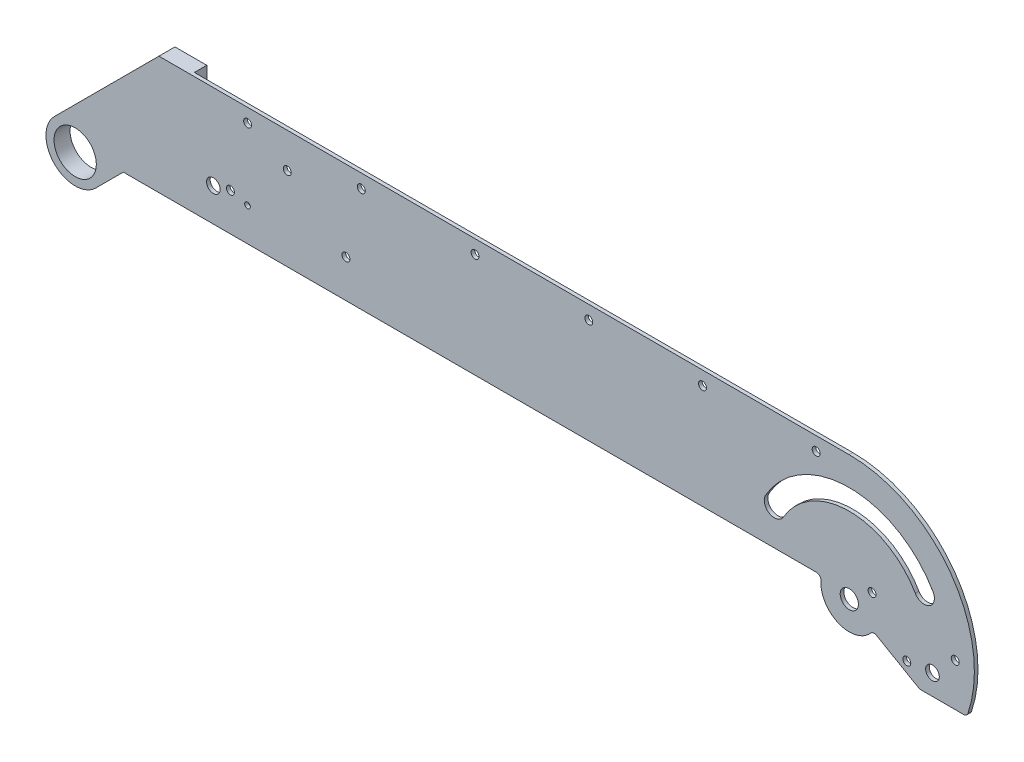
from build123d import *

# Parameters (mm, degrees)
SKETCH1_W           = 500
SKETCH1_H           = 150
SKETCH1_R           = 9.3
SKETCH1_R_2         = 3
SKETCH1_R_3         = 4
BOSS_EXTRUDE1_DEPTH = 1.5875
SKETCH3_W           = 500
SKETCH3_H           = 150
CUT_EXTRUDE1_DEPTH  = 7
SKETCH4_R           = 9.3
CUT_EXTRUDE2_DEPTH  = 10
FILLET1_R           = 2
SKETCH5_R           = 1.75
SKETCH5_R_2         = 1.25
SKETCH5_R_3         = 3
CUT_EXTRUDE3_DEPTH  = 10
CUT_EXTRUDE4_START  = -10
SKETCH6_R           = 4
SKETCH6_R_2         = 3
SKETCH6_R_3         = 1.75
CUT_EXTRUDE4_DEPTH  = 10
SKETCH7_R           = 1.75
CUT_EXTRUDE5_DEPTH  = 246.38
SKETCH4_3_R         = 9.3
BOSS_EXTRUDE2_DEPTH = 7.045


with BuildPart() as part:
    # Sketch1 → Boss-Extrude1 (new body)
    with BuildSketch(Plane.XY):
        with Locations((200, 0)):
            Rectangle(SKETCH1_W, SKETCH1_H)
        Circle(SKETCH1_R, mode=Mode.SUBTRACT)
        with BuildLine():
            ThreePointArc((303.594020264, 21.24999987), (340.400100069, 42.5), (377.206179805, 21.249999751))
            ThreePointArc((377.206179805, 21.249999751), (375.559064779, 15.102885357), (369.411950518, 16.750000881))
            ThreePointArc((369.411950518, 16.750000881), (340.40010055, 33.5), (311.388250032, 16.750001833))
            ThreePointArc((311.388250032, 16.750001833), (305.241135638, 15.102885116), (303.594020264, 21.24999987))
        make_face(mode=Mode.SUBTRACT)
        with Locations((376.9688, -9.7841)):
            Circle(SKETCH1_R_2, mode=Mode.SUBTRACT)
        with Locations((340.4001, 0)):
            Circle(SKETCH1_R_3, mode=Mode.SUBTRACT)
    extrude(amount=BOSS_EXTRUDE1_DEPTH)

    # Sketch3 → Cut-Extrude1 (cut)
    with BuildSketch(Plane.XY.offset(1.5875)):
        with Locations((200, 0)):
            Rectangle(SKETCH3_W, SKETCH3_H)
        with BuildLine():
            Line((36.827355724, 55), (340.4001, 55))
            ThreePointArc((340.4001, 55), (385.445219047, 31.558473506), (392.093016219, -18.7841))
            Line((392.093016219, -18.7841), (371.332419214, -18.7841))
            Line((371.332419214, -18.7841), (350.803013897, -6.930323401))
            ThreePointArc((350.803013897, -6.930323401), (335.360003988, -11.438856245), (328.2654389, 3))
            Line((328.2654389, 3), (21.172644276, 3))
            Line((21.172644276, 3), (9.086322138, -9.086322138))
            ThreePointArc((9.086322138, -9.086322138), (-9.086322138, -9.086322138), (-9.086322138, 9.086322138))
            Line((-9.086322138, 9.086322138), (36.827355724, 55))
        make_face(mode=Mode.SUBTRACT)
    extrude(amount=-CUT_EXTRUDE1_DEPTH, mode=Mode.SUBTRACT)

    # Sketch4 → Cut-Extrude2 (cut)
    # profile 1 of 2: a face of its own
    with BuildSketch(Plane.XY.offset(1.5875)):
        Polygon((36.827355724, 55), (30.827355724, 49), (50.827355724, 49), (50.827355724, 55), align=None)
    # profile 2 of 2: a face of its own
    with BuildSketch(Plane.XY.offset(1.5875)):
        with BuildLine():
            Line((23.112698372, 8), (6.470027048, 24.642671324))
            Line((6.470027048, 24.642671324), (-9.086322138, 9.086322138))
            ThreePointArc((-9.086322138, 9.086322138), (-9.086322138, -9.086322138), (9.086322138, -9.086322138))
            Line((9.086322138, -9.086322138), (21.172644276, 3))
            Line((21.172644276, 3), (41, 3))
            Line((41, 3), (41, 8))
            Line((41, 8), (23.112698372, 8))
        make_face()
        Circle(SKETCH4_R, mode=Mode.SUBTRACT)
    extrude(amount=-CUT_EXTRUDE2_DEPTH, mode=Mode.SUBTRACT)

    # Fillet1
    fillet1_edges = [part.edges().sort_by_distance(p)[0] for p in [
        (392.093016219, -18.7841, 0.79375),
        (328.2654389, 3, 0.79375),
        (350.803013897, -6.930323401, 0.79375),
    ]]
    fillet(fillet1_edges, radius=FILLET1_R)

    # Sketch5 → Cut-Extrude3 (cut)
    with BuildSketch(Plane.XY.offset(1.5875)):
        with Locations((17.470027048, 19.642671324)):
            Circle(SKETCH5_R)
        with Locations((42.470027048, 39.642671324)):
            Circle(SKETCH5_R)
        with Locations((93.270027048, 39.642671324)):
            Circle(SKETCH5_R)
        with Locations((68.270027048, 19.642671324)):
            Circle(SKETCH5_R)
        with Locations((119.070027048, 19.642671324)):
            Circle(SKETCH5_R)
        with Locations((75.770027048, 17.642671324)):
            Circle(SKETCH5_R_2)
        with Locations((60.770027048, 17.642671324)):
            Circle(SKETCH5_R_3)
    extrude(amount=-CUT_EXTRUDE3_DEPTH, mode=Mode.SUBTRACT)

    # Sketch6 → Cut-Extrude4 (cut)
    with BuildSketch(Plane.XY.offset(1.5875).offset(CUT_EXTRUDE4_START)):
        with Locations((340.4001, 0)):
            Circle(SKETCH6_R)
        with Locations((376.9688, -9.7841)):
            Circle(SKETCH6_R_2)
        with Locations((350.4001, 7.5)):
            Circle(SKETCH6_R_3)
        with Locations((386.9688, 0)):
            Circle(SKETCH6_R_3)
        with Locations((365.670778247, -10.944141097)):
            Circle(SKETCH6_R_3)
    extrude(amount=CUT_EXTRUDE4_DEPTH, mode=Mode.SUBTRACT)

    # Sketch7 → Cut-Extrude5 (cut)
    with BuildSketch(Plane.XY.offset(1.5875)):
        with Locations((75.827355724, 49)):
            Circle(SKETCH7_R)
        with Locations((125.827355724, 49)):
            Circle(SKETCH7_R)
        with Locations((175.827355724, 49)):
            Circle(SKETCH7_R)
        with Locations((225.827355724, 49)):
            Circle(SKETCH7_R)
        with Locations((275.827355724, 49)):
            Circle(SKETCH7_R)
        with Locations((325.827355724, 49)):
            Circle(SKETCH7_R)
    extrude(amount=-CUT_EXTRUDE5_DEPTH, mode=Mode.SUBTRACT)

    # Sketch4_3 → Boss-Extrude2 (add)
    with BuildSketch(Plane.XY.offset(1.5875)):
        with BuildLine():
            Line((41, 8), (50.827355724, 49))
            Line((50.827355724, 49), (50.827355724, 55))
            Line((50.827355724, 55), (36.827355724, 55))
            Line((36.827355724, 55), (-9.086322138, 9.086322138))
            ThreePointArc((-9.086322138, 9.086322138), (-9.086322138, -9.086322138), (9.086322138, -9.086322138))
            Line((9.086322138, -9.086322138), (21.172644276, 3))
            Line((21.172644276, 3), (41, 3))
            Line((41, 3), (41, 8))
        make_face()
        Circle(SKETCH4_3_R, mode=Mode.SUBTRACT)
    extrude(amount=-BOSS_EXTRUDE2_DEPTH)


solid = part.part
